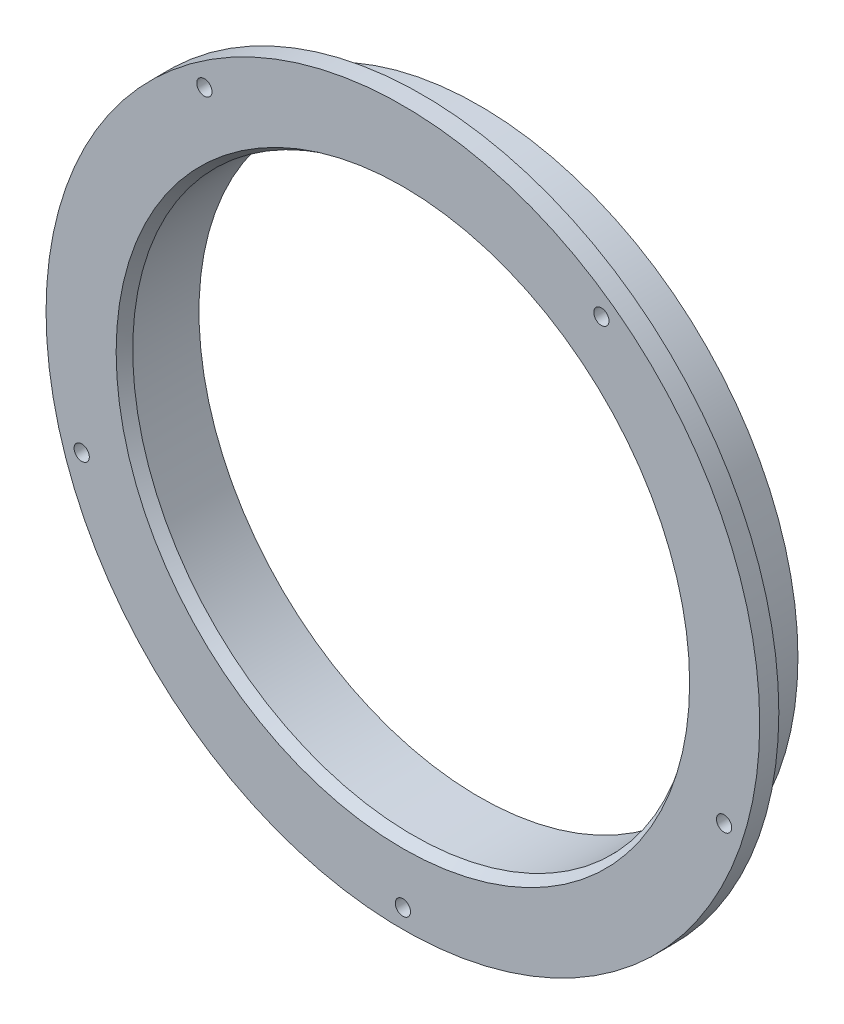
from build123d import *

# Parameters (mm, degrees)
F_6_CLEARANCE_HOLE1_D     = 3.7973
F_6_CLEARANCE_HOLE1_DEPTH = 25.4
F_6_CLEARANCE_HOLE1_TIP   = 1.140824014


with BuildPart() as part:
    # Sketch2 → Revolve1 (revolve)
    with BuildSketch(Plane(origin=(0, 0, 0), x_dir=(0, 0, -1), z_dir=(1, 0, 0))):
        Polygon((0, 71.4375), (2.54, 69.85), (19.05, 69.85), (19.05, 72.9615), (6.35, 72.9615), (6.35, 76.2635), (19.05, 76.2635), (19.05, 79.375), (4.7625, 79.375), (4.7625, 88.9), (0, 88.9), align=None)
    revolve(axis=Axis((0, 0, 0), (0, 0, -1)))

    # #6 Clearance Hole1
    with Locations(Plane(origin=(0, 0, -4.7625), x_dir=(-1, 0, 0), z_dir=(0, 0, -1))):
        with Locations((0, -84.1375), (80.01951764, -25.999917364), (49.454781665, 68.068667364), (-80.01951764, -25.999917364), (-49.454781665, 68.068667364)):
            Hole(F_6_CLEARANCE_HOLE1_D / 2, depth=F_6_CLEARANCE_HOLE1_DEPTH)
            with Locations((0, 0, -(F_6_CLEARANCE_HOLE1_DEPTH + F_6_CLEARANCE_HOLE1_TIP / 2))):  # 118° drill point
                Cone(0, F_6_CLEARANCE_HOLE1_D / 2, F_6_CLEARANCE_HOLE1_TIP, mode=Mode.SUBTRACT)


solid = part.part
